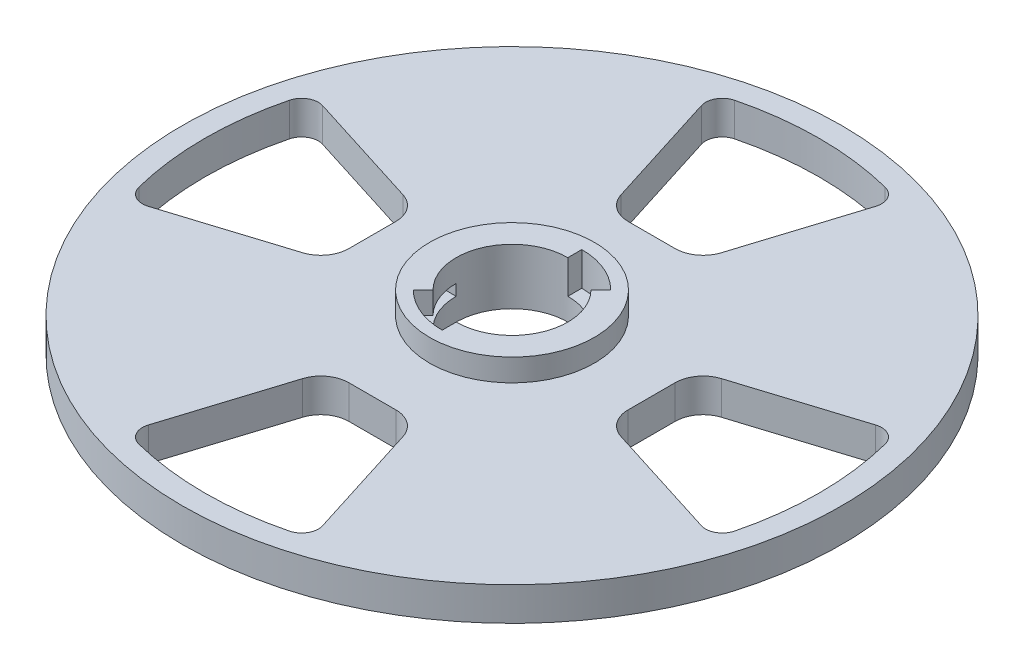
from build123d import *

# Parameters (mm, degrees)
SKETCH1_R           = 59
BOSS_EXTRUDE1_DEPTH = 6
CUT_EXTRUDE4_DEPTH  = 84.654049513
CIRPATTERN2_COUNT   = 4
SKETCH4_R           = 10
CUT_EXTRUDE6_DEPTH  = 10
BOSS_EXTRUDE2_START = 4
SKETCH5_R           = 14.75
SKETCH5_R_2         = 10
BOSS_EXTRUDE2_DEPTH = 4
CUT_EXTRUDE8_DEPTH  = 6
CUT_EXTRUDE9_START  = -4
CUT_EXTRUDE9_DEPTH  = 2
CIRPATTERN3_COUNT   = 2


with BuildPart() as part:
    # Sketch1 → Boss-Extrude1 (new body)
    with BuildSketch(Plane(origin=(0, 0, 0), x_dir=(1, 0, 0), z_dir=(0, 1, 0))):
        Circle(SKETCH1_R)
    extrude(amount=BOSS_EXTRUDE1_DEPTH)

    # Sketch2_3 → Cut-Extrude4 (cut, through all)
    with BuildSketch(Plane(origin=(0, 6, 0), x_dir=(1, 0, 0), z_dir=(0, 1, 0))):
        with BuildLine():
            Line((-15.610657267, 49.510679451), (-8.984902794, 28.496471002))
            ThreePointArc((-8.984902794, 28.496471002), (-7.172866282, 25.967776979), (-4.216318041, 25))
            Line((-4.216318041, 25), (4.216318041, 25))
            ThreePointArc((4.216318041, 25), (7.172866282, 25.967776979), (8.984902794, 28.496471002))
            Line((8.984902794, 28.496471002), (15.610657267, 49.510679451))
            ThreePointArc((15.610657267, 49.510679451), (15.369454974, 51.874258292), (13.485054862, 53.321227437))
            ThreePointArc((13.485054862, 53.321227437), (0, 55), (-13.485054862, 53.321227437))
            ThreePointArc((-13.485054862, 53.321227437), (-15.369454974, 51.874258292), (-15.610657267, 49.510679451))
        make_face()
    cut_extrude4 = extrude(amount=-CUT_EXTRUDE4_DEPTH, mode=Mode.SUBTRACT)

    # CirPattern2: Cut-Extrude4 ×4 about axis
    cirpattern2_axis = Axis((0, 6, 0), (0, -1, 0))
    for i in range(1, CIRPATTERN2_COUNT):
        add(cut_extrude4.rotate(cirpattern2_axis, i * 360 / CIRPATTERN2_COUNT), mode=Mode.SUBTRACT)

    # Sketch4 → Cut-Extrude6 (cut)
    with BuildSketch(Plane(origin=(0, 6, 0), x_dir=(1, 0, 0), z_dir=(0, 1, 0))):
        Circle(SKETCH4_R)
    extrude(amount=-CUT_EXTRUDE6_DEPTH, mode=Mode.SUBTRACT)

    # Sketch5 → Boss-Extrude2 (add)
    with BuildSketch(Plane(origin=(0, 6, 0), x_dir=(1, 0, 0), z_dir=(0, 1, 0)).offset(BOSS_EXTRUDE2_START)):
        Circle(SKETCH5_R)
        Circle(SKETCH5_R_2, mode=Mode.SUBTRACT)
    extrude(amount=-BOSS_EXTRUDE2_DEPTH)

    # Sketch6 → Cut-Extrude8 (cut)
    with BuildSketch(Plane(origin=(0, 10, 0), x_dir=(1, 0, 0), z_dir=(0, 1, 0))):
        with BuildLine():
            Line((0, 12.5), (0, 10))
            ThreePointArc((0, 10), (3.826834324, 9.238795325), (7.071067812, 7.071067812))
            Line((7.071067812, 7.071067812), (8.838834765, 8.838834765))
            ThreePointArc((8.838834765, 8.838834765), (4.783542905, 11.548494156), (0, 12.5))
        make_face()
    cut_extrude8 = extrude(amount=-CUT_EXTRUDE8_DEPTH, mode=Mode.SUBTRACT)

    # Sketch6_4 → Cut-Extrude9 (cut)
    with BuildSketch(Plane(origin=(0, 10, 0), x_dir=(1, 0, 0), z_dir=(0, 1, 0)).offset(CUT_EXTRUDE9_START)):
        with BuildLine():
            Line((8.838834765, 8.838834765), (7.071067812, 7.071067812))
            ThreePointArc((7.071067812, 7.071067812), (9.238795325, 3.826834324), (10, 0))
            Line((10, 0), (12.5, 0))
            ThreePointArc((12.5, 0), (11.548494156, 4.783542905), (8.838834765, 8.838834765))
        make_face()
    cut_extrude9 = extrude(amount=-CUT_EXTRUDE9_DEPTH, mode=Mode.SUBTRACT)

    # CirPattern3: Cut-Extrude8, Cut-Extrude9 ×2 about axis
    cirpattern3_axis = Axis((0, -4, 0), (0, 1, 0))
    add([cut_extrude8.rotate(cirpattern3_axis, i * 360 / CIRPATTERN3_COUNT) for i in range(1, CIRPATTERN3_COUNT)], mode=Mode.SUBTRACT)
    add([cut_extrude9.rotate(cirpattern3_axis, i * 360 / CIRPATTERN3_COUNT) for i in range(1, CIRPATTERN3_COUNT)], mode=Mode.SUBTRACT)


solid = part.part
